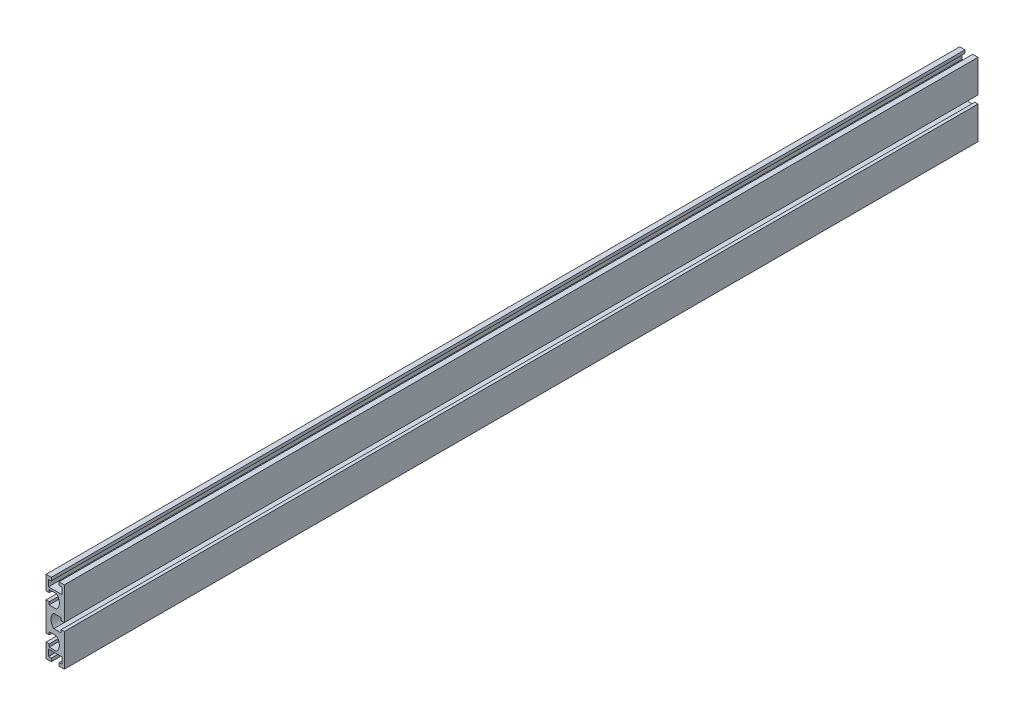
from build123d import *

# Parameters (mm, degrees)
EXTRUDE_1_DEPTH = 1000


with BuildPart() as part:
    # Эскиз1 → Бобышка-Вытянуть1 (new body)
    with BuildSketch(Plane.XY):
        with BuildLine():
            Line((-10, 40), (-10, 27.25))
            Line((-10, 27.25), (-10, 24.25))
            Line((-10, 24.25), (-6.5, 24.25))
            Line((-6.5, 24.25), (-6.5, 27.25))
            Line((-6.5, 27.25), (1.5, 27.25))
            ThreePointArc((1.5, 27.25), (4.612511343, 20), (1.5, 12.75))
            Line((1.5, 12.75), (-6.5, 12.75))
            Line((-6.5, 12.75), (-6.5, 15.75))
            Line((-6.5, 15.75), (-10, 15.75))
            Line((-10, 15.75), (-10, 12.75))
            Line((-10, 12.75), (-10, -12.75))
            Line((-10, -12.75), (-10, -15.75))
            Line((-10, -15.75), (-6.5, -15.75))
            Line((-6.5, -15.75), (-6.5, -12.75))
            Line((-6.5, -12.75), (1.5, -12.75))
            ThreePointArc((1.5, -12.75), (4.612511343, -20), (1.5, -27.25))
            Line((1.5, -27.25), (-6.5, -27.25))
            Line((-6.5, -27.25), (-6.5, -24.25))
            Line((-6.5, -24.25), (-10, -24.25))
            Line((-10, -24.25), (-10, -27.25))
            Line((-10, -27.25), (-10, -40))
            Line((-10, -40), (-4.25, -40))
            Line((-4.25, -40), (-4.25, -36.6))
            Line((-4.25, -36.6), (-7.25, -36.6))
            Line((-7.25, -36.6), (-7.25, -29.5))
            Line((-7.25, -29.5), (7.25, -29.5))
            Line((7.25, -29.5), (7.25, -36.6))
            Line((7.25, -36.6), (4.25, -36.6))
            Line((4.25, -36.6), (4.25, -40))
            Line((4.25, -40), (10, -40))
            Line((10, -40), (10, -7.25))
            Line((10, -7.25), (10, -4.25))
            Line((10, -4.25), (6.5, -4.25))
            Line((6.5, -4.25), (6.5, -7.25))
            Line((6.5, -7.25), (-1.5, -7.25))
            ThreePointArc((-1.5, -7.25), (-4.612511343, 0), (-1.5, 7.25))
            Line((-1.5, 7.25), (6.5, 7.25))
            Line((6.5, 7.25), (6.5, 4.25))
            Line((6.5, 4.25), (10, 4.25))
            Line((10, 4.25), (10, 7.25))
            Line((10, 7.25), (10, 40))
            Line((10, 40), (4.25, 40))
            Line((4.25, 40), (4.25, 36.6))
            Line((4.25, 36.6), (7.25, 36.6))
            Line((7.25, 36.6), (7.25, 29.5))
            Line((7.25, 29.5), (-7.25, 29.5))
            Line((-7.25, 29.5), (-7.25, 36.6))
            Line((-7.25, 36.6), (-4.25, 36.6))
            Line((-4.25, 36.6), (-4.25, 40))
            Line((-4.25, 40), (-10, 40))
        make_face()
    extrude(amount=EXTRUDE_1_DEPTH)


solid = part.part
